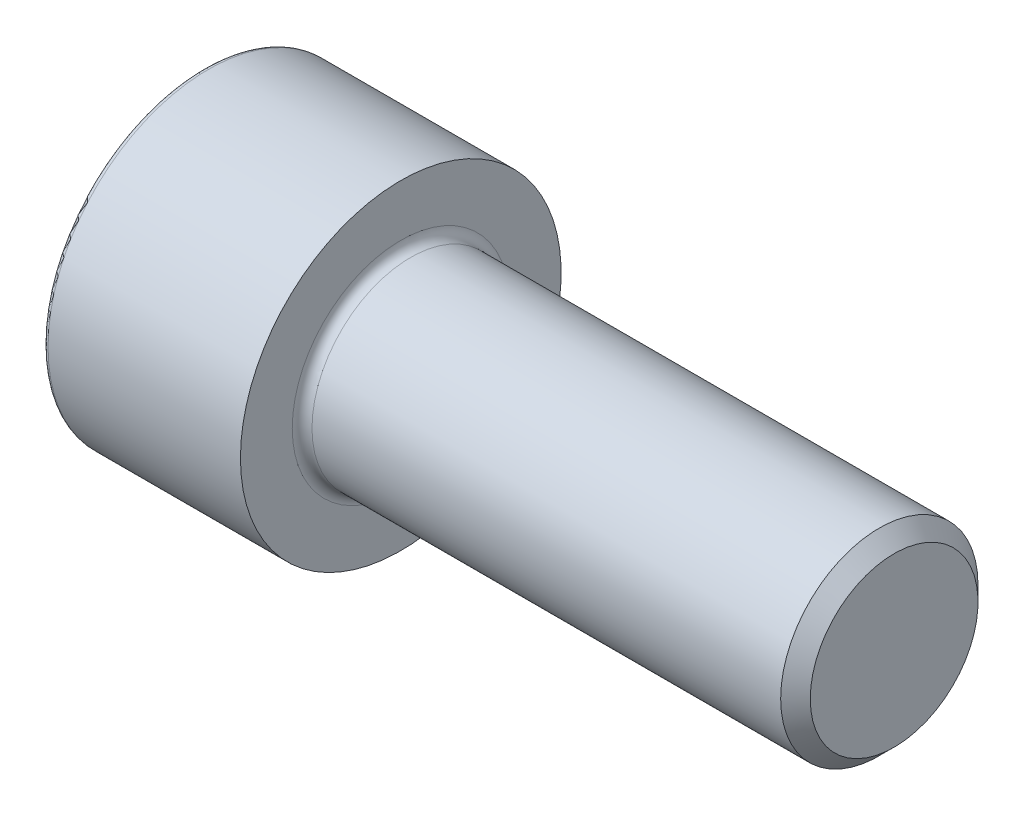
from build123d import *

# Parameters (mm, degrees)
MM_1_D              = 6
MM_1_DEPTH          = 4
MM_1_TIP            = 1.802581857
CUT_EXTRUDE_1_DEPTH = 4
FILLET_1_R          = 0.2
CHAMFER_1_SIZE      = 0.6
FILLET_2_R          = 0.4


with BuildPart() as part:
    # 草图1 → 旋转1 (revolve)
    with BuildSketch(Plane.XY):
        Polygon((0, 0), (0, 6.5), (8, 6.5), (8, 4), (28, 4), (28, 0), align=None)
    revolve(axis=Axis((0, 0, 0), (1, 0, 0)))

    # 大小mm 暗销孔1
    with Locations(Plane.ZY):
        with Locations((0, 0)):
            Hole(MM_1_D / 2, depth=MM_1_DEPTH)
            with Locations((0, 0, -(MM_1_DEPTH + MM_1_TIP / 2))):  # 118° drill point
                Cone(0, MM_1_D / 2, MM_1_TIP, mode=Mode.SUBTRACT)

    # 草图4 → 切除-拉伸1 (cut)
    with BuildSketch(Plane.ZY):
        Polygon((3, 1.732050808), (0, 3.464101615), (-3, 1.732050808), (-3, -1.732050808), (0, -3.464101615), (3, -1.732050808), align=None)
    extrude(amount=-CUT_EXTRUDE_1_DEPTH, mode=Mode.SUBTRACT)

    # 圆角1
    fillet_1_edges = [part.edges().sort_by_distance(p)[0] for p in [
        (0, -6.5, 0),
    ]]
    fillet(fillet_1_edges, radius=FILLET_1_R)

    # 倒角1
    chamfer_1_edges = [part.edges().sort_by_distance(p)[0] for p in [
        (28, -4, 0),
    ]]
    chamfer(chamfer_1_edges, length=CHAMFER_1_SIZE)

    # 圆角2
    fillet_2_edges = [part.edges().sort_by_distance(p)[0] for p in [
        (8, -4, 0),
    ]]
    fillet(fillet_2_edges, radius=FILLET_2_R)


solid = part.part
